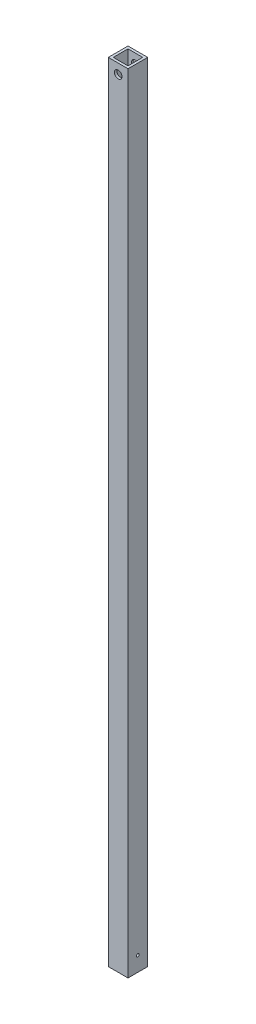
from build123d import *

# Parameters (mm, degrees)
SKETCH1_W               = 12.7
SKETCH1_H               = 12.7
SKETCH1_W_2             = 9.525
SKETCH1_H_2             = 9.525
EXTRUDE_THIN1_DEPTH     = 508
SKETCH3_R               = 2.4765
CUT_EXTRUDE2_DEPTH      = 1
CUT_EXTRUDE2_DEPTH_BACK = 13.7
CUT_EXTRUDE3_REACH      = 14.7
SKETCH4_R               = 0.889


with BuildPart() as part:
    # Sketch1 → Extrude-Thin1 (new body)
    with BuildSketch(Plane(origin=(0, 0, 0), x_dir=(1, 0, 0), z_dir=(0, 1, 0))):
        Rectangle(SKETCH1_W, SKETCH1_H)
        Rectangle(SKETCH1_W_2, SKETCH1_H_2, mode=Mode.SUBTRACT)
    extrude(amount=EXTRUDE_THIN1_DEPTH)

    # Sketch3 → Cut-Extrude2 (cut, two sides)
    with BuildSketch(Plane.XY.offset(6.35)) as cut_extrude2_sk:
        with Locations((0, 501.65)):
            Circle(SKETCH3_R)
    extrude(amount=CUT_EXTRUDE2_DEPTH, mode=Mode.SUBTRACT)
    extrude(cut_extrude2_sk.sketch, amount=-CUT_EXTRUDE2_DEPTH_BACK, mode=Mode.SUBTRACT)

    # Sketch4 → Cut-Extrude3 (cut, up to next)
    with BuildSketch(Plane(origin=(6.35, 0, 0), x_dir=(0, 0, -1), z_dir=(1, 0, 0)), mode=Mode.PRIVATE) as cut_extrude3_sk1:
        with Locations((0, 9.525)):
            Circle(SKETCH4_R)
    cut_extrude3_tool1 = extrude(cut_extrude3_sk1.sketch, amount=-CUT_EXTRUDE3_REACH, mode=Mode.PRIVATE) & part.part
    add(cut_extrude3_tool1.solids().sort_by_distance((6.35, 9.525, 0))[0], mode=Mode.SUBTRACT)


solid = part.part
